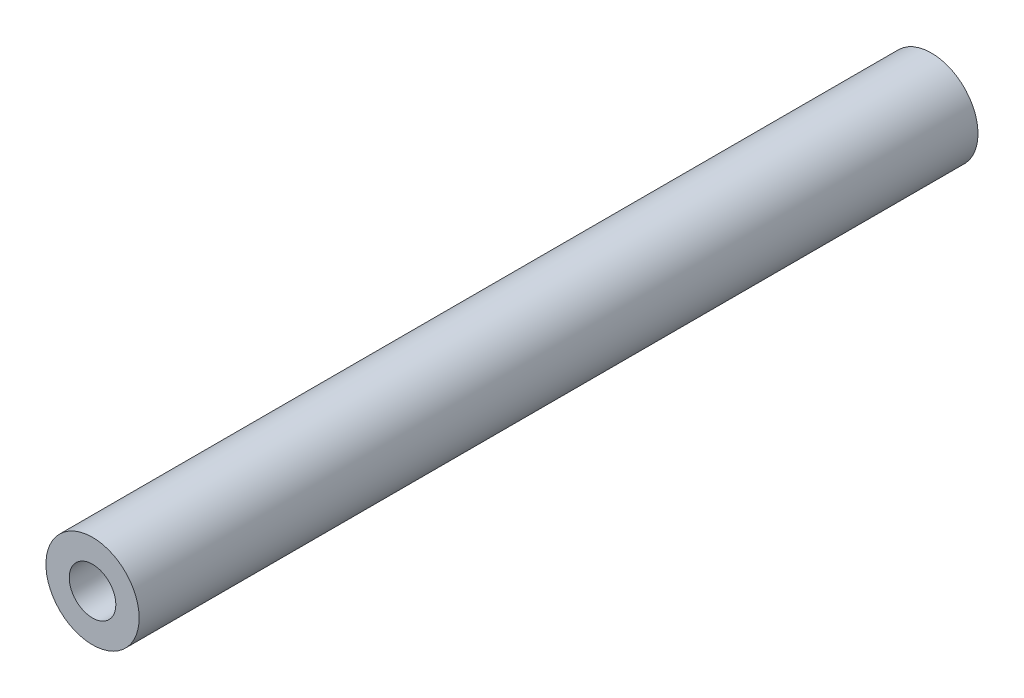
from build123d import *

# Parameters (mm, degrees)
ESQUISSE1_R        = 2.5
ESQUISSE1_R_2      = 1.25
BOSS_EXTRU_1_DEPTH = 45


with BuildPart() as part:
    # Esquisse1 → Boss.-Extru.1 (new body)
    with BuildSketch(Plane.XY):
        Circle(ESQUISSE1_R)
        Circle(ESQUISSE1_R_2, mode=Mode.SUBTRACT)
    extrude(amount=BOSS_EXTRU_1_DEPTH)


solid = part.part
